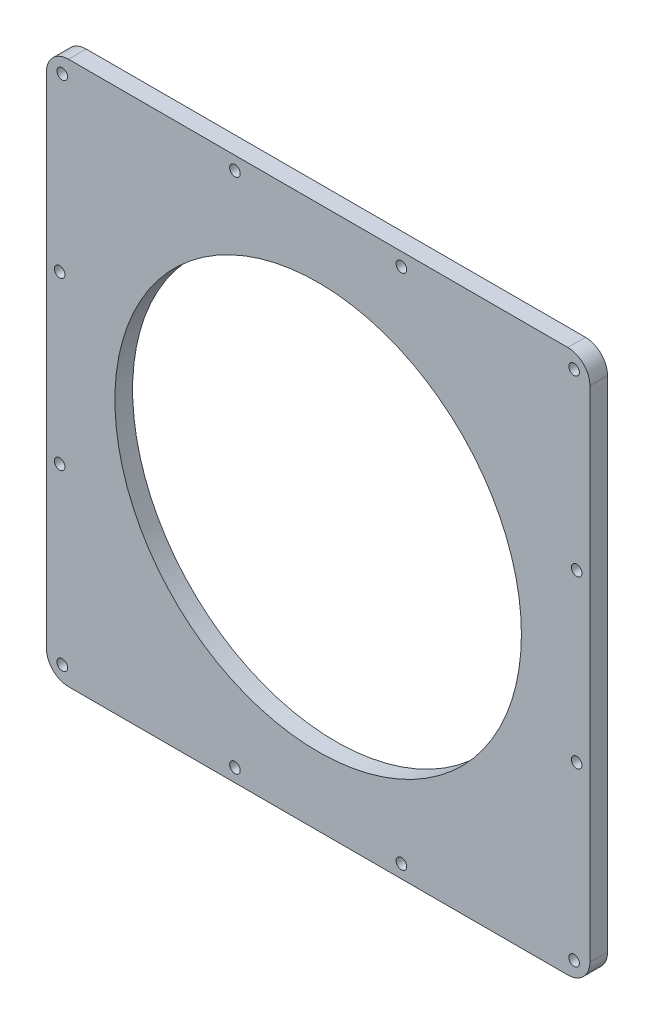
from build123d import *

# Parameters (mm, degrees)
SKETCH1_W                = 123
SKETCH1_H                = 123
SKETCH1_R                = 46
BOSS_EXTRUDE1_DEPTH      = 2
FILLET1_R                = 5
M2_CLEARANCE_HOLE1_D     = 2.4
M2_CLEARANCE_HOLE1_DEPTH = 4


with BuildPart() as part:
    # Sketch1 → Boss-Extrude1 (new body, symmetric)
    with BuildSketch(Plane.XY):
        Rectangle(SKETCH1_W, SKETCH1_H)
        Circle(SKETCH1_R, mode=Mode.SUBTRACT)
    extrude(amount=BOSS_EXTRUDE1_DEPTH, both=True)

    # Fillet1
    fillet1_edges = [part.edges().sort_by_distance(p)[0] for p in [
        (-61.5, -61.5, 0),
        (-61.5, 61.5, 0),
        (61.5, 61.5, 0),
        (61.5, -61.5, 0),
    ]]
    fillet(fillet1_edges, radius=FILLET1_R)

    # M2 Clearance Hole1
    with Locations(Plane.XY.offset(2)):
        with Locations((58.5, -18.833333333), (-57.914213562, 57.914213562), (57.914213562, 57.914213562), (57.914213562, -57.914213562), (-57.914213562, -57.914213562), (-18.833333333, -58.5), (18.833333333, -58.5), (-58.5, -18.833333333), (-58.5, 18.833333333), (-18.833333333, 58.5), (18.833333333, 58.5), (58.5, 18.833333333)):
            Hole(M2_CLEARANCE_HOLE1_D / 2, depth=M2_CLEARANCE_HOLE1_DEPTH)


solid = part.part
